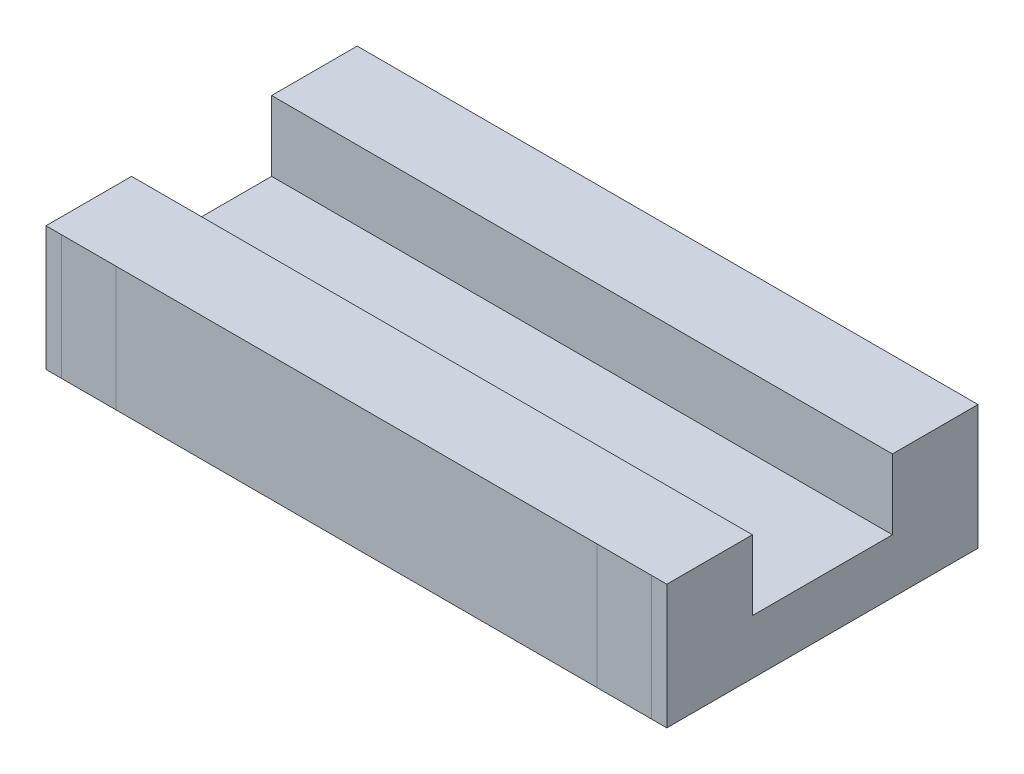
from build123d import *

# Parameters (mm, degrees)
SKETCH_1_W          = 39.9
SKETCH_1_H          = 20
EXTRUDE_1_DEPTH     = 8
SKETCH_2_W          = 39.9
SKETCH_2_H          = 9
CUT_EXTRUDE_1_DEPTH = 4.5
SKETCH_3_R          = 1.5
CUT_EXTRUDE_2_DEPTH = 4


with BuildPart() as part:
    # 草图1 → 凸台-拉伸1 (new body)
    with BuildSketch(Plane(origin=(0, 0, 0), x_dir=(1, 0, 0), z_dir=(0, 1, 0))):
        Rectangle(SKETCH_1_W, SKETCH_1_H)
    extrude(amount=EXTRUDE_1_DEPTH)

    # 草图2 → 切除-拉伸1 (cut)
    with BuildSketch(Plane(origin=(0, 8, 0), x_dir=(1, 0, 0), z_dir=(0, 1, 0))):
        Rectangle(SKETCH_2_W, SKETCH_2_H)
    extrude(amount=-CUT_EXTRUDE_1_DEPTH, mode=Mode.SUBTRACT)

    # 草图3 → 切除-拉伸2 (cut)
    with BuildSketch(Plane.XZ):
        with Locations((-8, 7.5)):
            Circle(SKETCH_3_R)
        with Locations((8, 7.5)):
            Circle(SKETCH_3_R)
        with Locations((8, -7.5)):
            Circle(SKETCH_3_R)
        with Locations((-8, -7.5)):
            Circle(SKETCH_3_R)
    extrude(amount=-CUT_EXTRUDE_2_DEPTH, mode=Mode.SUBTRACT)


solid = part.part
